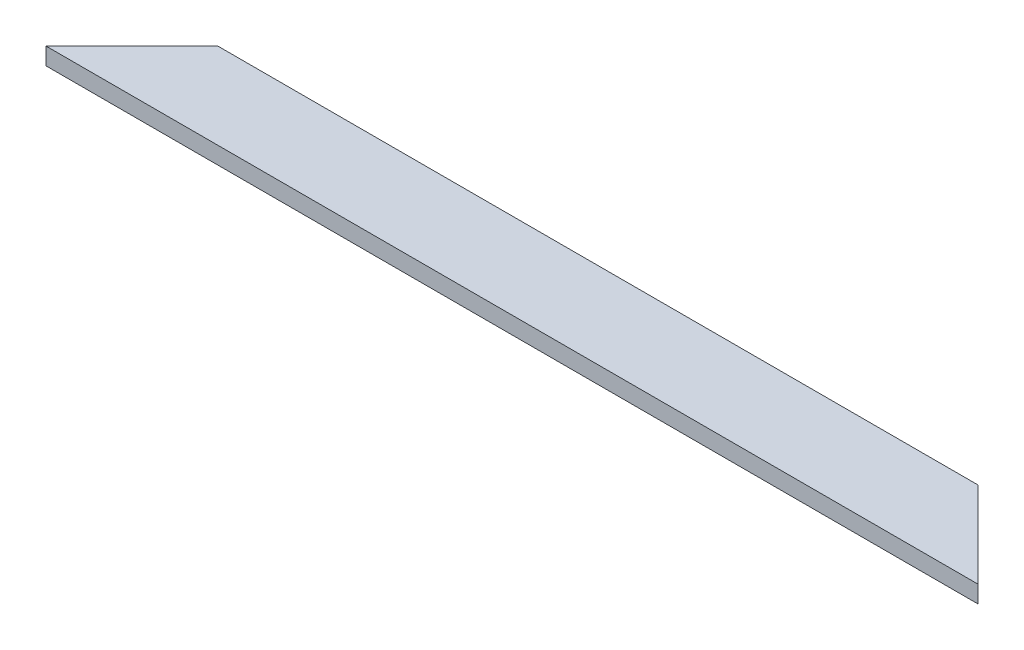
from build123d import *

# Parameters (mm, degrees)
SKETCH_1_W          = 20
SKETCH_1_H          = 4
EXTRUDE_1_DEPTH     = 217
SKETCH_2_OUTSIDE_W  = 262.592
SKETCH_2_OUTSIDE_H  = 65.592
CUT_EXTRUDE_1_DEPTH = 10


with BuildPart() as part:
    # Эскиз1 → Бобышка-Вытянуть1 (new body)
    with BuildSketch(Plane(origin=(0, 0, 0), x_dir=(0, 0, -1), z_dir=(1, 0, 0))):
        with Locations((10, 2)):
            Rectangle(SKETCH_1_W, SKETCH_1_H)
    extrude(amount=EXTRUDE_1_DEPTH)

    # Эскиз2 outside → Вырез-Вытянуть1 (cut)
    with BuildSketch(Plane(origin=(0, 4, 0), x_dir=(1, 0, 0), z_dir=(0, 1, 0))):
        with Locations((108.5, 10)):
            Rectangle(SKETCH_2_OUTSIDE_W, SKETCH_2_OUTSIDE_H)
        Polygon((0, 0), (20, 20), (197, 20), (217, 0), align=None, mode=Mode.SUBTRACT)
    extrude(amount=-CUT_EXTRUDE_1_DEPTH, mode=Mode.SUBTRACT)


solid = part.part
